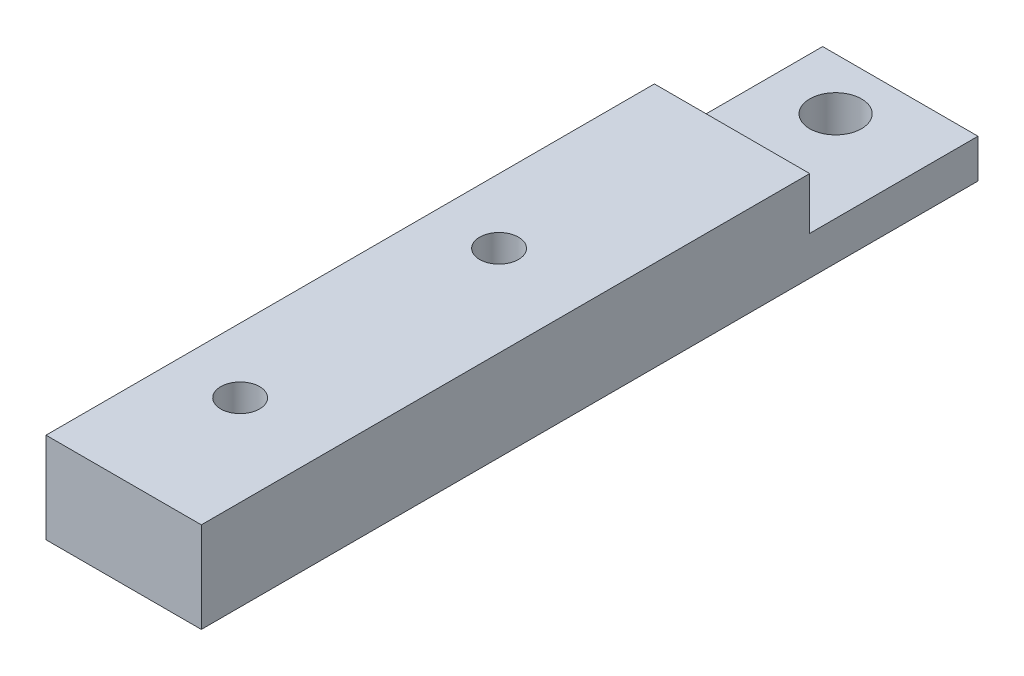
from build123d import *

# Parameters (mm, degrees)
SKETCH1_W           = 10
SKETCH1_H           = 60
BOSS_EXTRUDE1_DEPTH = 7
SKETCH2_W           = 10
SKETCH2_H           = 13
CUT_EXTRUDE1_DEPTH  = 4
SKETCH3_R           = 2
CUT_EXTRUDE2_DEPTH  = 4
SKETCH4_R           = 1.5
CUT_EXTRUDE3_DEPTH  = 14
BOSS_EXTRUDE2_DEPTH = 2


with BuildPart() as part:
    # Sketch1 → Boss-Extrude1 (new body)
    with BuildSketch(Plane(origin=(0, 0, 0), x_dir=(1, 0, 0), z_dir=(0, 1, 0))):
        Rectangle(SKETCH1_W, SKETCH1_H)
    extrude(amount=BOSS_EXTRUDE1_DEPTH)

    # Sketch2 → Cut-Extrude1 (cut)
    with BuildSketch(Plane(origin=(0, 7, 0), x_dir=(1, 0, 0), z_dir=(0, 1, 0))):
        with Locations((0, 23.5)):
            Rectangle(SKETCH2_W, SKETCH2_H)
    extrude(amount=-CUT_EXTRUDE1_DEPTH, mode=Mode.SUBTRACT)

    # Sketch3 → Cut-Extrude2 (cut)
    with BuildSketch(Plane(origin=(0, 3, 0), x_dir=(1, 0, 0), z_dir=(0, 1, 0))):
        with Locations((0, 26)):
            Circle(SKETCH3_R)
    extrude(amount=-CUT_EXTRUDE2_DEPTH, mode=Mode.SUBTRACT)

    # Sketch4 → Cut-Extrude3 (cut)
    with BuildSketch(Plane(origin=(0, 0, 0), x_dir=(1, 0, 0), z_dir=(0, 1, 0))):
        Circle(SKETCH4_R)
        with Locations((0, -20)):
            Circle(SKETCH4_R)
    extrude(amount=CUT_EXTRUDE3_DEPTH, mode=Mode.SUBTRACT)

    # Sketch5 → Boss-Extrude2 (add)
    with BuildSketch(Plane(origin=(5, 0, 0), x_dir=(0, 0, -1), z_dir=(1, 0, 0))):
        Polygon((-30, 7), (-30, 0), (30, 0), (30, 3), (17, 3), (17, 7), align=None)
    extrude(amount=BOSS_EXTRUDE2_DEPTH)


solid = part.part
